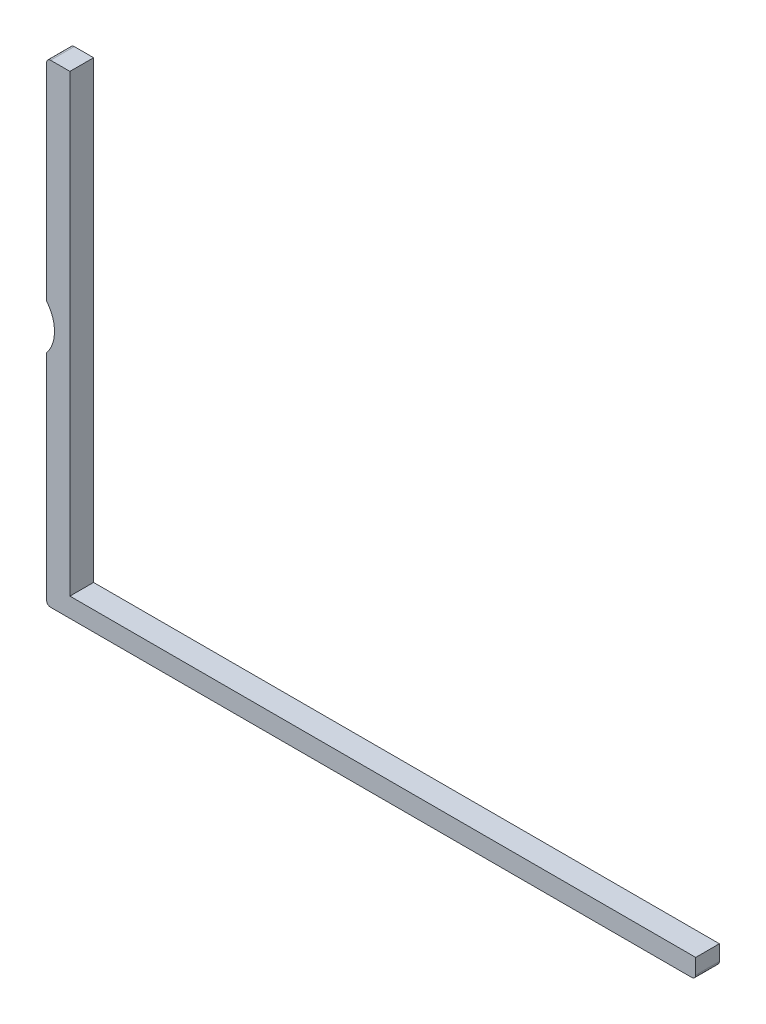
from build123d import *

# Parameters (mm, degrees)
SALIENTE_EXTRUIR1_DEPTH = 3
REDONDEO1_R             = 0.5


with BuildPart() as part:
    # Croquis1 → Saliente-Extruir1 (new body)
    with BuildSketch(Plane.XY):
        with BuildLine():
            Line((0, 0), (82.2, 0))
            Line((82.2, 0), (82.2, 2.45))
            Line((82.2, 2.45), (2.95, 2.45))
            Line((2.95, 2.45), (2.95, 60))
            Line((2.95, 60), (0, 60))
            Line((0, 60), (0, 33.328427125))
            ThreePointArc((0, 33.328427125), (1, 30.5), (0, 27.671572875))
            Line((0, 27.671572875), (0, 0))
        make_face()
    extrude(amount=SALIENTE_EXTRUIR1_DEPTH)

    # Redondeo1
    redondeo1_edges = [part.edges().sort_by_distance(p)[0] for p in [
        (0, 60, 1.5),
        (82.2, 0, 1.5),
        (0, 0, 1.5),
    ]]
    fillet(redondeo1_edges, radius=REDONDEO1_R)


solid = part.part
